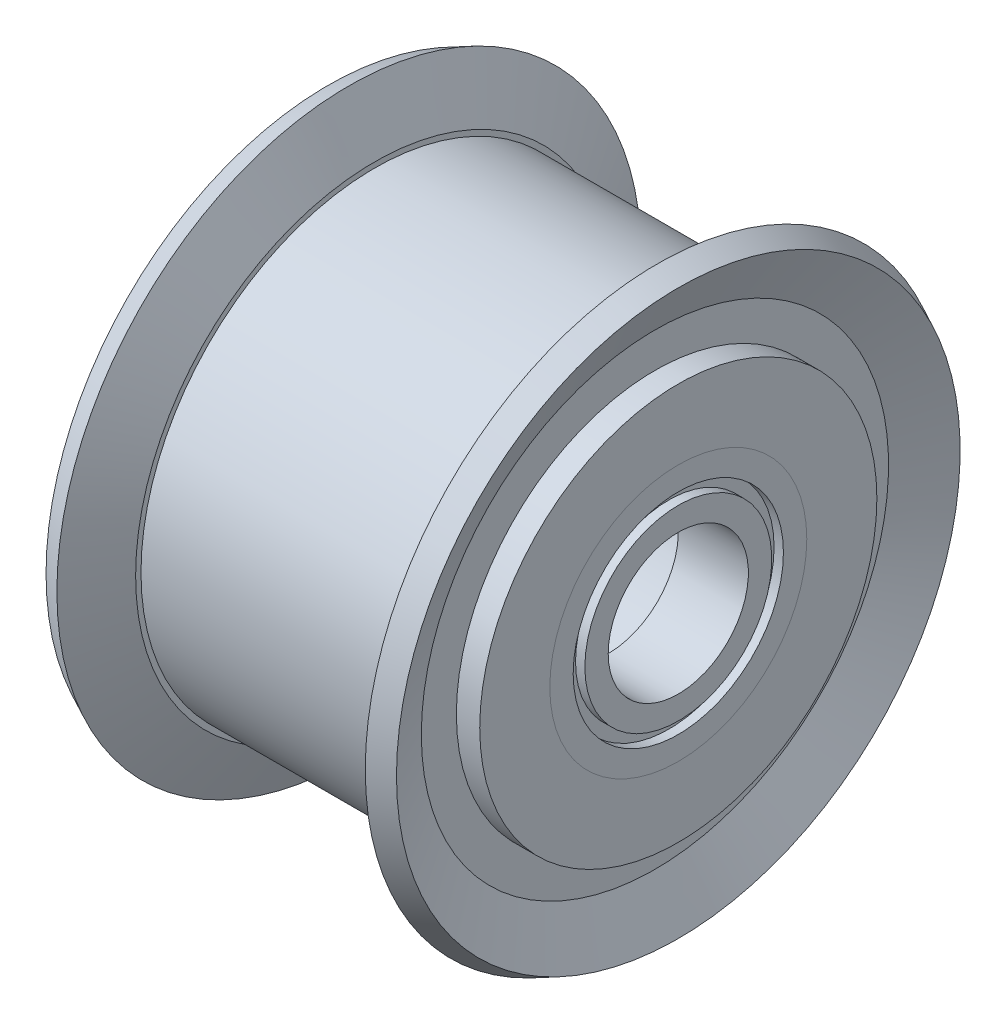
from build123d import *


with BuildPart() as part:
    # Sketch1 → Revolve1 (revolve)
    with BuildSketch(Plane.XY):
        Polygon((-5.5, 10), (5.5, 10), (5.5, 8.5), (7.5, 8.5), (7.5, 5.5), (4.5, 5.5), (4.5, 5), (-4.5, 5), (-4.5, 5.5), (-7.5, 5.5), (-7.5, 8.5), (-5.5, 8.5), align=None)
    revolve(axis=Axis((0, 0, 0), (1, 0, 0)))


with BuildPart() as body_2:
    # Sketch2 → Revolve2 (revolve)
    with BuildSketch(Plane.XY):
        Polygon((5.5, 10.229491938), (5.5, 8.5), (6.5, 8.5), (6.5, 10), (7.5, 12.063979803), (6.60006312, 12.5), align=None)
        Polygon((-6.5, 8.5), (-6.5, 10), (-7.5, 12.063979803), (-6.60006312, 12.5), (-5.5, 10.229491938), (-5.5, 8.5), align=None)
    revolve(axis=Axis((0, 0, 0), (1, 0, 0)))


with BuildPart() as body_3:
    # Sketch3 → Revolve3 (revolve)
    with BuildSketch(Plane.XY):
        Polygon((4.5, 5.5), (7.5, 5.5), (7.5, 4.5), (7.1, 4.5), (7.1, 4), (7.5, 4), (7.5, 3), (4.5, 3), (4.5, 4), (4.9, 4), (4.9, 4.5), (4.5, 4.5), align=None)
        Polygon((-4.5, 4.5), (-4.9, 4.5), (-4.9, 4), (-4.5, 4), (-4.5, 3), (-7.5, 3), (-7.5, 4), (-7.1, 4), (-7.1, 4.5), (-7.5, 4.5), (-7.5, 5.5), (-4.5, 5.5), align=None)
    revolve(axis=Axis((0, 0, 0), (1, 0, 0)))


solid = Compound([part.part, body_2.part, body_3.part])
